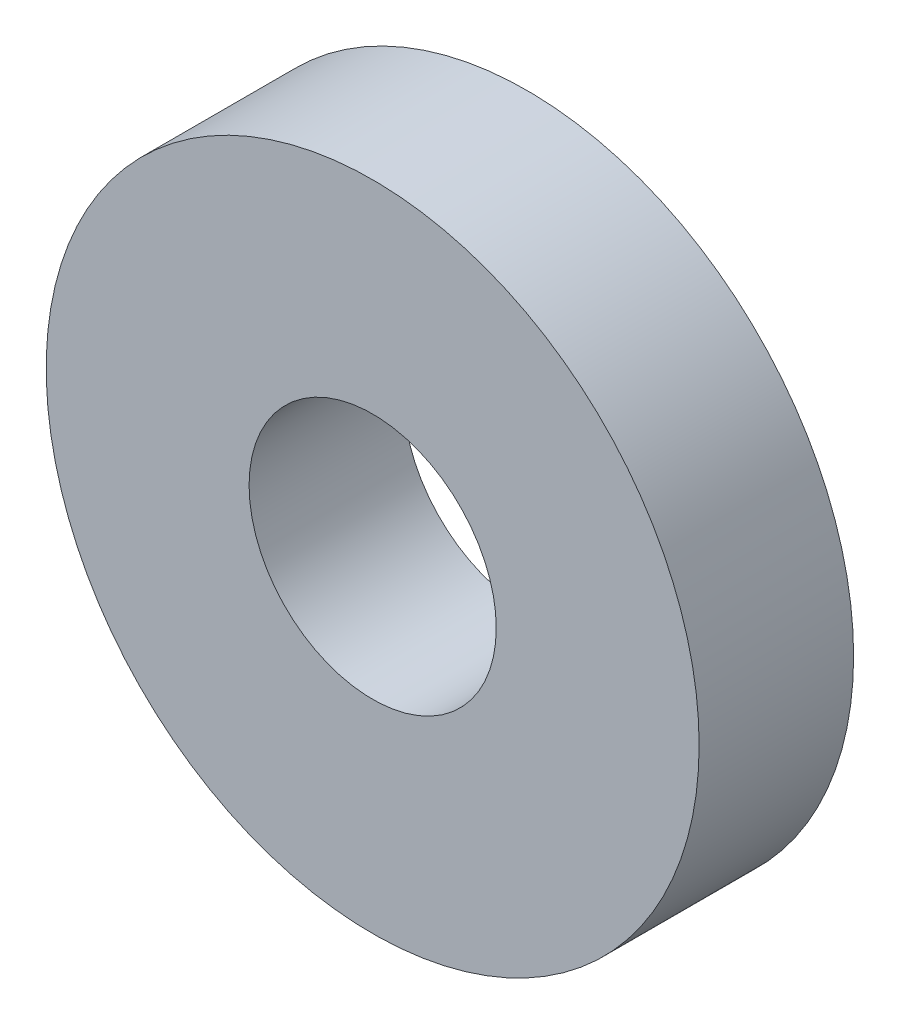
from build123d import *

# Parameters (mm, degrees)
SKETCH_1_R      = 158.5
SKETCH_1_R_2    = 60
EXTRUDE_1_DEPTH = 75


with BuildPart() as part:
    # Эскиз1 → Бобышка-Вытянуть1 (new body)
    with BuildSketch(Plane.XY):
        Circle(SKETCH_1_R)
        Circle(SKETCH_1_R_2, mode=Mode.SUBTRACT)
    extrude(amount=EXTRUDE_1_DEPTH)


solid = part.part
